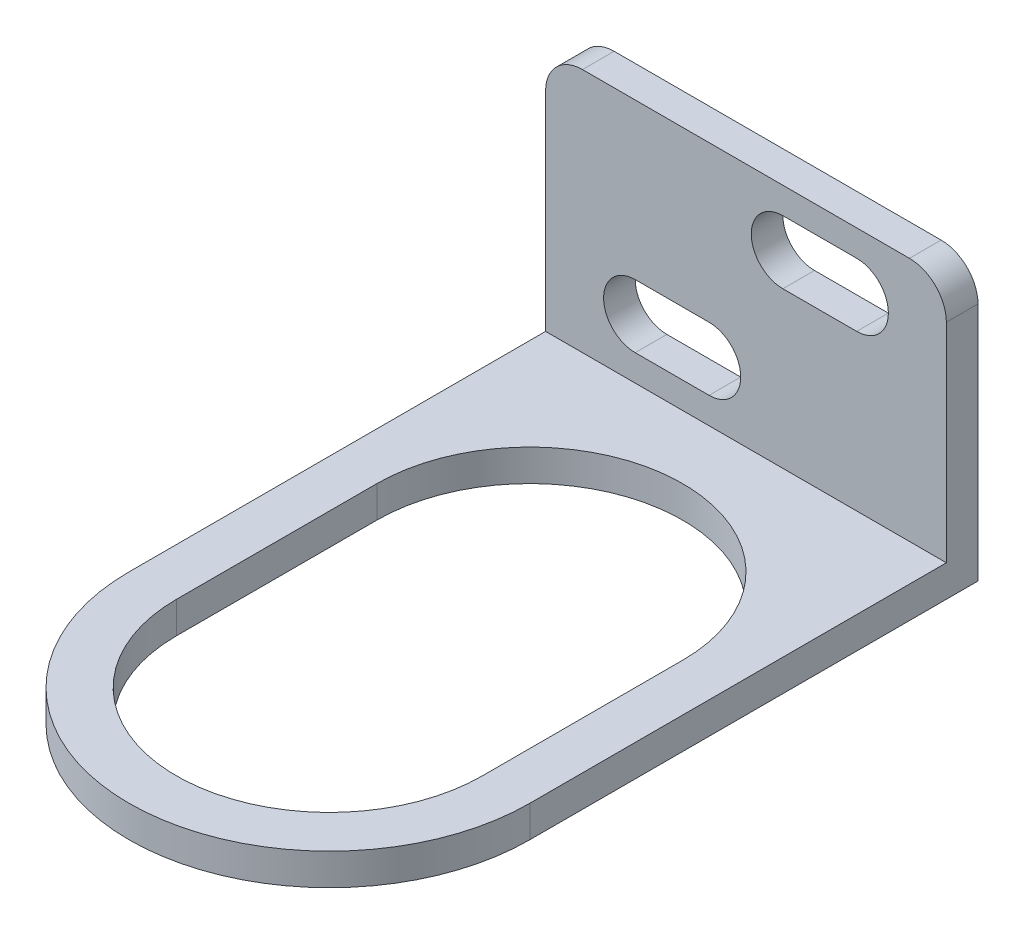
from build123d import *

# Parameters (mm, degrees)
EXTRUDE_THIN1_DEPTH = 38
CUT_EXTRUDE1_DEPTH  = 4
FILLET1_R           = 3.5
FILLET2_R           = 3.5
CUT_EXTRUDE2_DEPTH  = 4


with BuildPart() as part:
    # Sketch2 → Extrude-Thin1 (new body)
    with BuildSketch(Plane(origin=(0, 0, 0), x_dir=(0, 0, -1), z_dir=(1, 0, 0))):
        Polygon((-63, 0), (0, 0), (0, 26.25), (-3, 26.25), (-3, 3), (-63, 3), align=None)
    extrude(amount=-EXTRUDE_THIN1_DEPTH)

    # Sketch3 → Cut-Extrude1 (cut, through all)
    with BuildSketch(Plane.XY.offset(3)):
        with BuildLine():
            Line((-29.5, 11.5), (-22.5, 11.5))
            ThreePointArc((-22.5, 11.5), (-19.5, 8.5), (-22.5, 5.5))
            Line((-22.5, 5.5), (-29.5, 5.5))
            ThreePointArc((-29.5, 5.5), (-32.5, 8.5), (-29.5, 11.5))
        make_face()
        with BuildLine():
            Line((-15.5, 23.75), (-8.5, 23.75))
            ThreePointArc((-8.5, 23.75), (-5.5, 20.75), (-8.5, 17.75))
            Line((-8.5, 17.75), (-15.5, 17.75))
            ThreePointArc((-15.5, 17.75), (-18.5, 20.75), (-15.5, 23.75))
        make_face()
    extrude(amount=-CUT_EXTRUDE1_DEPTH, mode=Mode.SUBTRACT)

    # Fillet1
    fillet1_edges = [part.edges().sort_by_distance(p)[0] for p in [
        (-38, 26.25, 1.5),
    ]]
    fillet(fillet1_edges, radius=FILLET1_R)

    # Fillet2
    fillet2_edges = [part.edges().sort_by_distance(p)[0] for p in [
        (0, 26.25, 1.5),
    ]]
    fillet(fillet2_edges, radius=FILLET2_R)

    # Sketch4 → Cut-Extrude2 (cut, through all)
    with BuildSketch(Plane(origin=(0, 3, 0), x_dir=(1, 0, 0), z_dir=(0, 1, 0))):
        with BuildLine():
            Line((-33.5, -23.5), (-33.5, -42.5))
            ThreePointArc((-33.5, -42.5), (-19, -57), (-4.5, -42.5))
            Line((-4.5, -42.5), (-4.5, -23.5))
            ThreePointArc((-4.5, -23.5), (-19, -9), (-33.5, -23.5))
        make_face()
        with BuildLine():
            Line((0, -63), (0, -42.5))
            ThreePointArc((0, -42.5), (-19, -61.5), (-38, -42.5))
            Line((-38, -42.5), (-38, -63))
            Line((-38, -63), (0, -63))
        make_face()
    extrude(amount=-CUT_EXTRUDE2_DEPTH, mode=Mode.SUBTRACT)


solid = part.part
